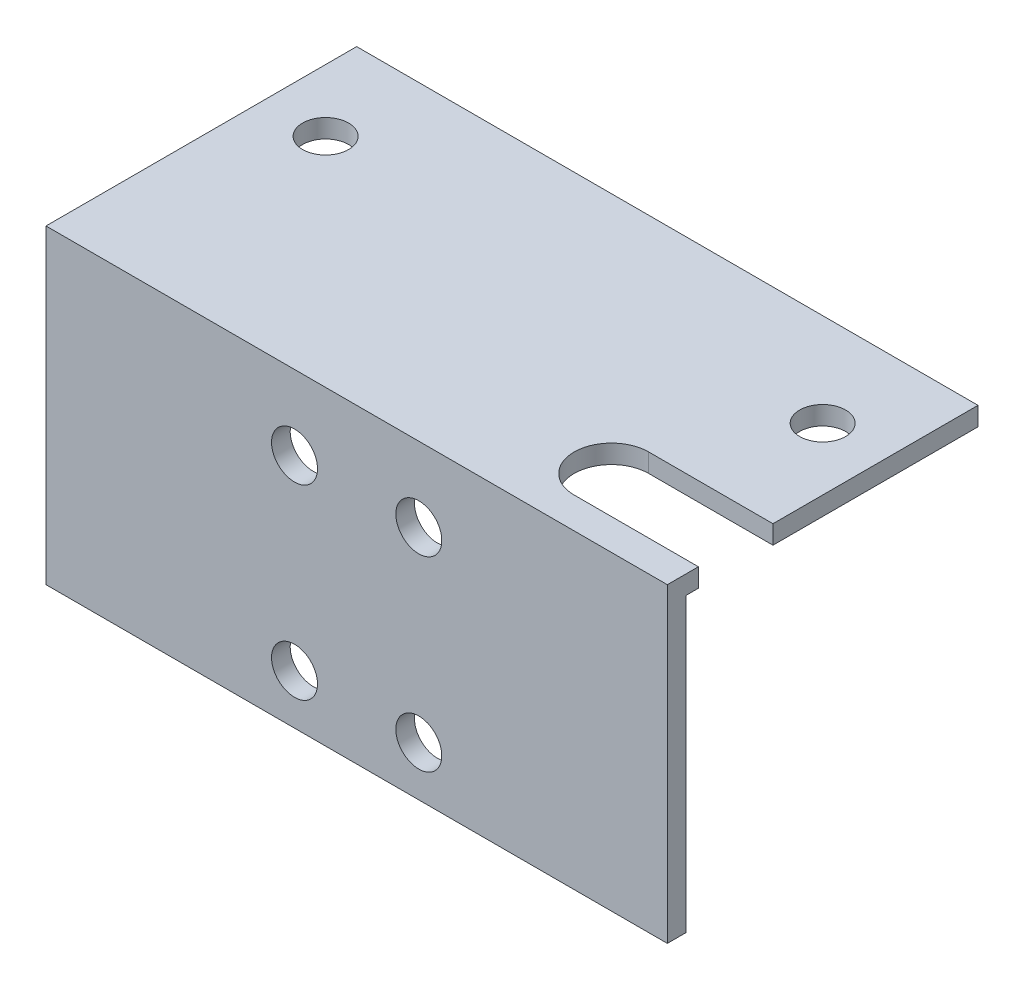
from build123d import *

# Parameters (mm, degrees)
SKETCH1_W           = 50
SKETCH1_H           = 25
SKETCH1_R           = 1.85
BOSS_EXTRUDE1_DEPTH = 1.5
SKETCH2_W           = 50
SKETCH2_H           = 1.5
BOSS_EXTRUDE2_DEPTH = 23.5
SKETCH3_R           = 1.85
CUT_EXTRUDE1_DEPTH  = 23.5
CUT_EXTRUDE2_DEPTH  = 10


with BuildPart() as part:
    # Sketch1 → Boss-Extrude1 (new body)
    with BuildSketch(Plane(origin=(0, 0, 0), x_dir=(1, 0, 0), z_dir=(0, 1, 0))):
        with Locations((25, 12.5)):
            Rectangle(SKETCH1_W, SKETCH1_H)
        with Locations((5, 17.5)):
            Circle(SKETCH1_R, mode=Mode.SUBTRACT)
        with Locations((45, 17.5)):
            Circle(SKETCH1_R, mode=Mode.SUBTRACT)
    extrude(amount=BOSS_EXTRUDE1_DEPTH)

    # Sketch2 → Boss-Extrude2 (add)
    with BuildSketch(Plane.XZ):
        with Locations((25, -0.75)):
            Rectangle(SKETCH2_W, SKETCH2_H)
    extrude(amount=BOSS_EXTRUDE2_DEPTH)

    # Sketch3 → Cut-Extrude1 (cut)
    with BuildSketch(Plane(origin=(0, 0, -1.5), x_dir=(-1, 0, 0), z_dir=(0, 0, -1))):
        with Locations((-20, -19.5)):
            Circle(SKETCH3_R)
        with Locations((-30, -19.5)):
            Circle(SKETCH3_R)
        with Locations((-20, -4.5)):
            Circle(SKETCH3_R)
        with Locations((-30, -4.5)):
            Circle(SKETCH3_R)
    extrude(amount=-CUT_EXTRUDE1_DEPTH, mode=Mode.SUBTRACT)

    # Sketch4 → Cut-Extrude2 (cut)
    with BuildSketch(Plane.XZ):
        with BuildLine():
            Line((50, -8.5), (40, -8.5))
            ThreePointArc((40, -8.5), (37, -5.5), (40, -2.5))
            Line((40, -2.5), (50, -2.5))
            ThreePointArc((50, -2.5), (53, -5.5), (50, -8.5))
        make_face()
    extrude(amount=-CUT_EXTRUDE2_DEPTH, mode=Mode.SUBTRACT)


solid = part.part
